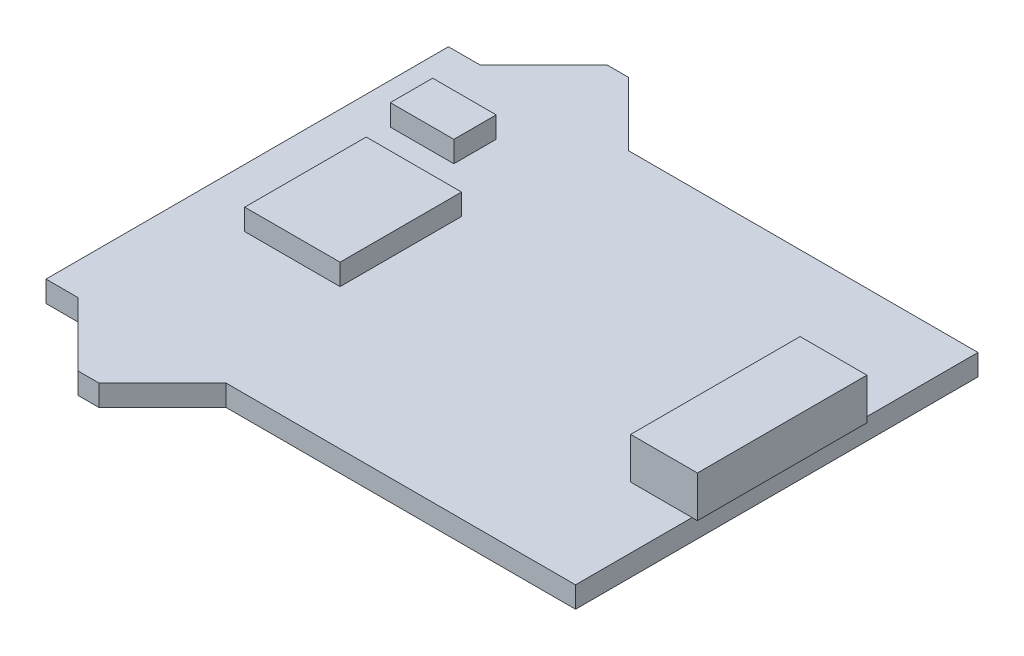
from build123d import *

# Parameters (mm, degrees)
BOSS_EXTRUDE1_DEPTH = 1.000000032
SKETCH2_W           = 4.49999989
SKETCH2_H           = 5.735208424
SKETCH2_W_2         = 3
SKETCH2_H_2         = 2
BOSS_EXTRUDE2_DEPTH = 1
SKETCH3_W           = 3.154000042
SKETCH3_H           = 8.000000002
BOSS_EXTRUDE3_DEPTH = 1.94999991


with BuildPart() as part:
    # Sketch1 → Boss-Extrude1 (new body)
    with BuildSketch(Plane(origin=(0, 0, 0), x_dir=(1, 0, 0), z_dir=(0, 1, 0))):
        Polygon((-3.499999985, 9.50000005), (-0.499999889, 12.500000146), (0.499999889, 12.500000146), (3.499999985, 9.50000005), (4.999999906, 9.50000005), (20.000000132, 9.50000005), (20.000000132, -9.50000005), (4.999999906, -9.50000005), (3.499999985, -9.50000005), (0.499999889, -12.500000146), (-0.499999889, -12.500000146), (-3.499999985, -9.50000005), (-4.999999906, -9.50000005), (-4.999999906, 9.50000005), align=None)
    extrude(amount=-BOSS_EXTRUDE1_DEPTH)

    # Sketch2 → Boss-Extrude2 (add)
    with BuildSketch(Plane(origin=(0, 0, 0), x_dir=(1, 0, 0), z_dir=(0, 1, 0))):
        Rectangle(SKETCH2_W, SKETCH2_H)
        with Locations((-1.5875, 5.842)):
            Rectangle(SKETCH2_W_2, SKETCH2_H_2)
    extrude(amount=BOSS_EXTRUDE2_DEPTH)

    # Sketch3 → Boss-Extrude3 (add)
    with BuildSketch(Plane(origin=(0, 0, 0), x_dir=(1, 0, 0), z_dir=(0, 1, 0))):
        with Locations((18.677000111, 0)):
            Rectangle(SKETCH3_W, SKETCH3_H)
    extrude(amount=BOSS_EXTRUDE3_DEPTH)


solid = part.part
